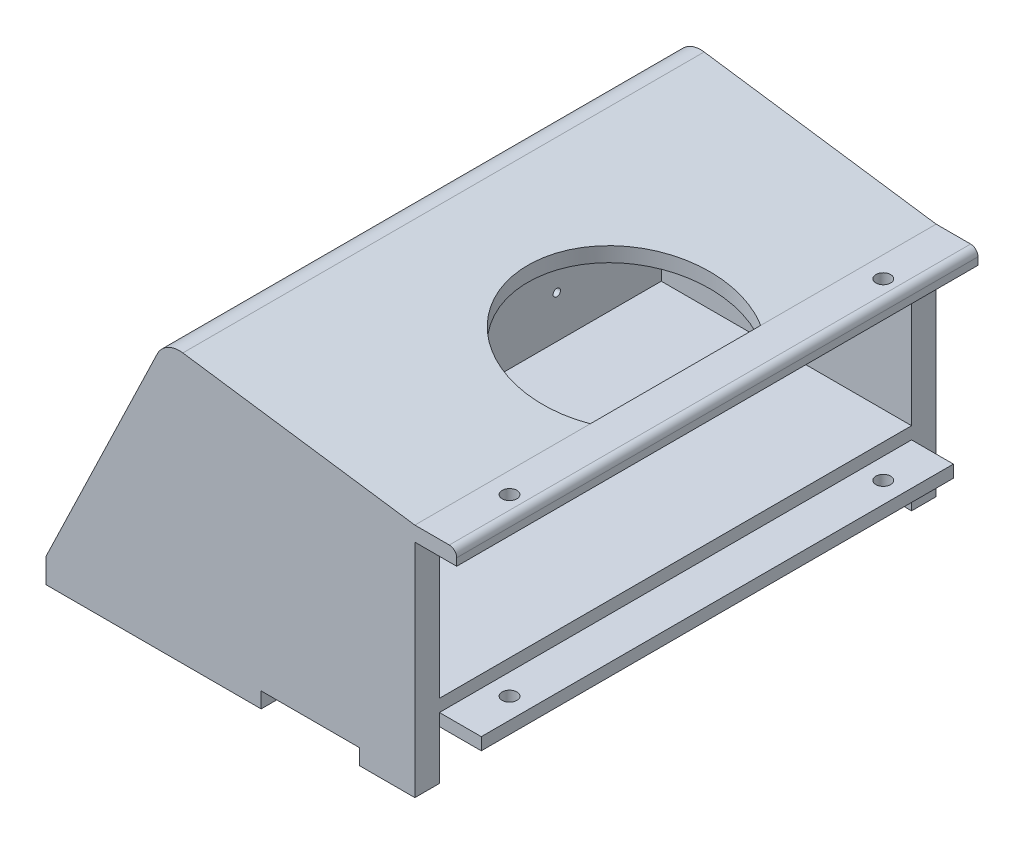
from build123d import *

# Parameters (mm, degrees)
BOSS_EXTRUDE1_DEPTH     = 212
CUT_EXTRUDE1_REACH      = 92.491
SKETCH2_W               = 17.02
SKETCH2_H               = 10
SKETCH3_R               = 1.5
CUT_EXTRUDE2_DEPTH      = 15
SKETCH4_R               = 3
CUT_EXTRUDE3_DEPTH      = 111.491488024
CUT_EXTRUDE3_DEPTH_BACK = 1
SKETCH5_W               = 30
SKETCH5_H               = 15
CUT_EXTRUDE4_DEPTH      = 15
SKETCH6_R               = 3
CUT_EXTRUDE5_DEPTH      = 15.491488024
CUT_EXTRUDE5_DEPTH_BACK = 97
BOSS_EXTRUDE2_DEPTH     = 10
BOSS_EXTRUDE3_DEPTH     = 10
SKETCH9_W               = 40
SKETCH9_H               = 6.35
CUT_EXTRUDE6_DEPTH      = 1
CUT_EXTRUDE6_DEPTH_BACK = 213
CUT_EXTRUDE9_DEPTH      = 25
CUT_EXTRUDE9_DEPTH_BACK = 27
SKETCH11_R              = 7.5
CUT_EXTRUDE10_DEPTH     = 101.491488024
SKETCH12_R              = 4
CUT_EXTRUDE11_DEPTH     = 44.22
FILLET2_R               = 10
FILLET3_R               = 3


with BuildPart() as part:
    # Sketch1 → Boss-Extrude1 (new body)
    with BuildSketch(Plane.XY):
        Polygon((0, 0), (0, -6), (-17.02, -6), (-118.8, 8.518342212), (-118.8, -66), (-17.02, -66), (-17.02, -71), (0, -71), (0, -76), (-130.862615106, -76), (-147.02, -96), (-167.02, -96), (-167.02, -86), (-118.611740262, 14.491488024), (-17.02, 0), align=None)
    extrude(amount=BOSS_EXTRUDE1_DEPTH)

    # Sketch2 → Cut-Extrude1 (cut, up to next)
    with BuildSketch(Plane.XZ.offset(76), mode=Mode.PRIVATE) as cut_extrude1_sk1:
        with Locations((-8.51, 207)):
            Rectangle(SKETCH2_W, SKETCH2_H)
    cut_extrude1_tool1 = extrude(cut_extrude1_sk1.sketch, amount=-CUT_EXTRUDE1_REACH, mode=Mode.PRIVATE) & part.part
    add(cut_extrude1_tool1.solids().sort_by_distance((-8.51, -76, 207))[0], mode=Mode.SUBTRACT)
    # Sketch2 → Cut-Extrude1 (cut, up to next)
    with BuildSketch(Plane.XZ.offset(76), mode=Mode.PRIVATE) as cut_extrude1_sk2:
        with Locations((-8.51, 5)):
            Rectangle(SKETCH2_W, SKETCH2_H)
    cut_extrude1_tool2 = extrude(cut_extrude1_sk2.sketch, amount=-CUT_EXTRUDE1_REACH, mode=Mode.PRIVATE) & part.part
    add(cut_extrude1_tool2.solids().sort_by_distance((-8.51, -76, 5))[0], mode=Mode.SUBTRACT)

    # Sketch3 → Cut-Extrude2 (cut)
    with BuildSketch(Plane(origin=(-118.8, 0, 0), x_dir=(0, 0, -1), z_dir=(1, 0, 0))):
        with Locations((-159.5, -8.731657788)):
            Circle(SKETCH3_R)
        with Locations((-159.5, -48.731657788)):
            Circle(SKETCH3_R)
        with Locations((-52.5, -48.731657788)):
            Circle(SKETCH3_R)
        with Locations((-52.5, -8.731657788)):
            Circle(SKETCH3_R)
    extrude(amount=-CUT_EXTRUDE2_DEPTH, mode=Mode.SUBTRACT)

    # Sketch4 → Cut-Extrude3 (cut, two sides)
    with BuildSketch(Plane(origin=(0, -96, 0), x_dir=(1, 0, 0), z_dir=(0, 1, 0))) as cut_extrude3_sk:
        with Locations((-157.02, -187)):
            Circle(SKETCH4_R)
        with Locations((-157.02, -25)):
            Circle(SKETCH4_R)
    extrude(amount=CUT_EXTRUDE3_DEPTH, mode=Mode.SUBTRACT)
    extrude(cut_extrude3_sk.sketch, amount=-CUT_EXTRUDE3_DEPTH_BACK, mode=Mode.SUBTRACT)

    # Sketch5 → Cut-Extrude4 (cut)
    with BuildSketch(Plane(origin=(0, -66, 0), x_dir=(1, 0, 0), z_dir=(0, 1, 0))):
        with Locations((-98.8, -184.31184426)):
            Rectangle(SKETCH5_W, SKETCH5_H)
    extrude(amount=-CUT_EXTRUDE4_DEPTH, mode=Mode.SUBTRACT)

    # Sketch6 → Cut-Extrude5 (cut, two sides)
    with BuildSketch(Plane(origin=(0, 0, 0), x_dir=(1, 0, 0), z_dir=(0, 1, 0))) as cut_extrude5_sk:
        with Locations((-8.52, -30)):
            Circle(SKETCH6_R)
        with Locations((-8.52, -182)):
            Circle(SKETCH6_R)
    extrude(amount=CUT_EXTRUDE5_DEPTH, mode=Mode.SUBTRACT)
    extrude(cut_extrude5_sk.sketch, amount=-CUT_EXTRUDE5_DEPTH_BACK, mode=Mode.SUBTRACT)

    # Sketch7 → Boss-Extrude2 (add)
    with BuildSketch(Plane.XY.offset(212)):
        Polygon((-17.02, 0), (-118.611740262, 14.491488024), (-167.02, -86), (-167.02, -96), (-17.02, -96), align=None)
    extrude(amount=-BOSS_EXTRUDE2_DEPTH)

    # Sketch8 → Boss-Extrude3 (add)
    with BuildSketch(Plane(origin=(0, 0, 0), x_dir=(-1, 0, 0), z_dir=(0, 0, -1))):
        Polygon((167.02, -86), (167.02, -96), (17.02, -96), (17.02, 0), (118.611740262, 14.491488024), align=None)
    extrude(amount=-BOSS_EXTRUDE3_DEPTH)

    # Sketch9 → Cut-Extrude6 (cut, two sides)
    with BuildSketch(Plane.XY.offset(212)) as cut_extrude6_sk:
        with Locations((-59.52, -92.825)):
            Rectangle(SKETCH9_W, SKETCH9_H)
    extrude(amount=CUT_EXTRUDE6_DEPTH, mode=Mode.SUBTRACT)
    extrude(cut_extrude6_sk.sketch, amount=-CUT_EXTRUDE6_DEPTH_BACK, mode=Mode.SUBTRACT)

    # Sketch10 → Cut-Extrude9 (cut, two sides)
    with BuildSketch(Plane(origin=(0, 0, 0), x_dir=(1, 0, 0), z_dir=(0, 1, 0))) as cut_extrude9_sk:
        with BuildLine():
            Line((-17.02, -140.641016151), (-17.02, -71.358983849))
            ThreePointArc((-17.02, -71.358983849), (-77.02, -106), (-17.02, -140.641016151))
        make_face()
    extrude(amount=CUT_EXTRUDE9_DEPTH, mode=Mode.SUBTRACT)
    extrude(cut_extrude9_sk.sketch, amount=-CUT_EXTRUDE9_DEPTH_BACK, mode=Mode.SUBTRACT)

    # Sketch11 → Cut-Extrude10 (cut, through all)
    with BuildSketch(Plane(origin=(0, -86, 0), x_dir=(-1, 0, 0), z_dir=(0, -1, 0))):
        with Locations((157.02, -25)):
            Circle(SKETCH11_R)
        with Locations((157.02, -187)):
            Circle(SKETCH11_R)
    extrude(amount=-CUT_EXTRUDE10_DEPTH, mode=Mode.SUBTRACT)

    # Sketch12 → Cut-Extrude11 (cut, through all)
    with BuildSketch(Plane(origin=(-123.8, 0, 0), x_dir=(0, 0, -1), z_dir=(1, 0, 0))):
        with Locations((-159.5, -8.731657788)):
            Circle(SKETCH12_R)
        with Locations((-52.5, -8.731657788)):
            Circle(SKETCH12_R)
    extrude(amount=-CUT_EXTRUDE11_DEPTH, mode=Mode.SUBTRACT)

    # Fillet2
    fillet2_edges = [part.edges().sort_by_distance(p)[0] for p in [
        (-118.611740262, 14.491488024, 106),
    ]]
    fillet(fillet2_edges, radius=FILLET2_R)

    # Fillet3
    fillet3_edges = [part.edges().sort_by_distance(p)[0] for p in [
        (0, 0, 106),
    ]]
    fillet(fillet3_edges, radius=FILLET3_R)


solid = part.part
